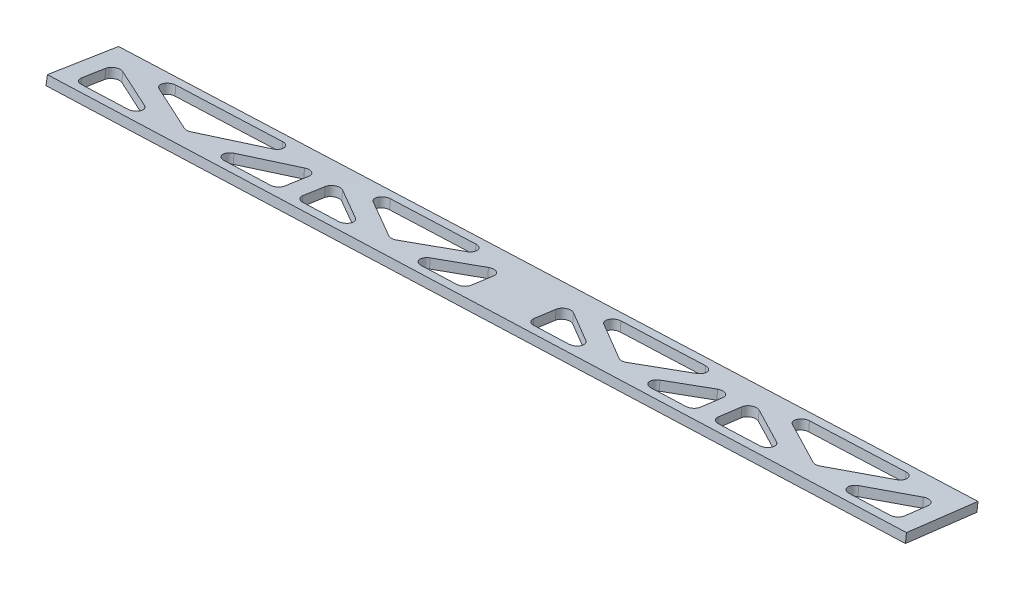
from build123d import *

# Parameters (mm, degrees)
CUT_EXTRUDE2_DEPTH      = 14.066824819
CUT_EXTRUDE2_DEPTH_BACK = 18.094309049
FILLET1_R               = 2.54


with BuildPart() as part:
    # Sketch1 → Loft1 section 0
    with BuildSketch(Plane(origin=(0, 0, 0), x_dir=(0, 0, -1), z_dir=(1, 0, 0))):
        Polygon((5.924524399, -3.873191473), (31.13772874, -6.947980383), (31.522077354, -3.79632984), (6.308873012, -0.72154093), align=None)
    # Sketch2 → Loft1 section 1
    with BuildSketch(Plane(origin=(-301.244, 0, 0), x_dir=(0, 0, -1), z_dir=(1, 0, 0))):
        Polygon((29.66416581, -14.543476344), (4.571250508, -10.60576106), (4.079036097, -13.742375473), (29.171951399, -17.680090757), align=None)
    loft()

    # Sketch3 → Cut-Extrude2 (cut, two sides)
    with BuildSketch(Plane(origin=(-0.001577966, 0.047082695, -0.005741807), x_dir=(0.999447069, 0.033005385, -0.004025057), z_dir=(-0.03324991, 0.992096975, -0.120987747))) as cut_extrude2_sk:
        Polygon((-295.088054809, 24.431002398), (-266.18852591, 9.058250028), (-295.088054809, 9.00759554), align=None)
        Polygon((-288.350897254, 28.039754294), (-259.455267738, 12.669076153), (-230.559638223, 28.146992017), align=None)
        Polygon((-252.708932717, 9.079145758), (-223.812085822, 24.55771371), (-223.812085822, 9.118088647), align=None)
        Polygon((-193.794207841, 9.18514127), (-217.462085822, 24.397057709), (-217.462085822, 9.14365671), align=None)
        Polygon((-211.606738616, 28.182161104), (-187.942878373, 12.972826962), (-164.27901813, 28.269982637), align=None)
        Polygon((-182.073610805, 9.205684886), (-158.41376702, 24.500244181), (-158.41376702, 9.247155364), align=None)
        Polygon((-136.436196911, 24.535208515), (-113.031441325, 9.326700553), (-136.436196911, 9.285677188), align=None)
        Polygon((-130.625742607, 28.332429808), (-107.22500602, 13.126533409), (-83.824269433, 28.419274835), align=None)
        Polygon((-101.400662031, 9.347086739), (-78.003943175, 24.637202516), (-78.003943175, 9.388096017), align=None)
        Polygon((-71.653943175, 24.769175799), (-45.299064717, 9.445420442), (-71.653943175, 9.399226164), align=None)
        Polygon((-65.357498741, 28.453541858), (-39.00669553, 13.132156009), (-12.65906818, 28.551329305), align=None)
        Polygon((-32.696565695, 9.467509838), (-6.352252536, 24.884743602), (-6.349077075, 9.513691163), align=None)
    extrude(amount=CUT_EXTRUDE2_DEPTH, mode=Mode.SUBTRACT)
    extrude(cut_extrude2_sk.sketch, amount=-CUT_EXTRUDE2_DEPTH_BACK, mode=Mode.SUBTRACT)

    # Fillet1
    fillet1_edges = [part.edges().sort_by_distance(p)[0] for p in [
        (-6.2943144, -2.890468589, -9.231677641),
        (-6.297121855, -4.762239274, -24.488343434),
        (-32.626920354, -3.763865657, -9.078642064),
        (-65.264700348, -7.29218722, -27.775050617),
        (-12.59983325, -5.432665724, -28.100334033),
        (-38.93294423, -4.434163063, -12.688694498),
        (-45.22230037, -4.18163824, -9.005441009),
        (-71.558128809, -7.040103837, -24.094130356),
        (-71.562290537, -5.055323566, -8.852357229),
        (-130.491371552, -9.595353444, -27.37216664),
        (-107.111721102, -6.739167183, -12.401931457),
        (-83.719709011, -7.94382528, -27.661061461),
        (-112.916411898, -6.427079868, -8.612006519),
        (-136.307943572, -7.20303167, -8.476050715),
        (-136.300077651, -9.283758908, -23.584812517),
        (-158.263959453, -10.050741704, -23.456054418),
        (-181.919569661, -8.716142508, -8.210939593),
        (-158.273095438, -7.931688182, -8.348382718),
        (-164.12321007, -10.782945632, -27.164428133),
        (-211.420781224, -12.453148406, -26.872272173),
        (-187.782835855, -9.448124704, -11.916724733),
        (-193.633543399, -9.1047537, -8.142852046),
        (-217.288046094, -9.889509749, -8.005357938),
        (-217.275501898, -12.11029387, -23.10093793),
        (-223.621401289, -12.356915369, -23.232708305),
        (-252.514975291, -11.057825116, -7.797891198),
        (-223.634469643, -10.097948352, -7.954181044),
        (-230.361606629, -13.122016417, -26.755273052),
        (-288.11604692, -15.161592143, -26.398511458),
        (-259.253962783, -11.822999005, -11.321103982),
        (-265.986947205, -11.50520723, -7.722281725),
        (-294.852925834, -14.844261773, -22.801722528),
        (-294.870141219, -12.463520696, -7.55438416),
        (-101.292203818, -6.04148631, -8.679567464),
        (-77.908703174, -5.26583553, -8.815472366),
        (-77.904207933, -7.245938386, -23.936077491),
    ]]
    fillet(fillet1_edges, radius=FILLET1_R)


solid = part.part
